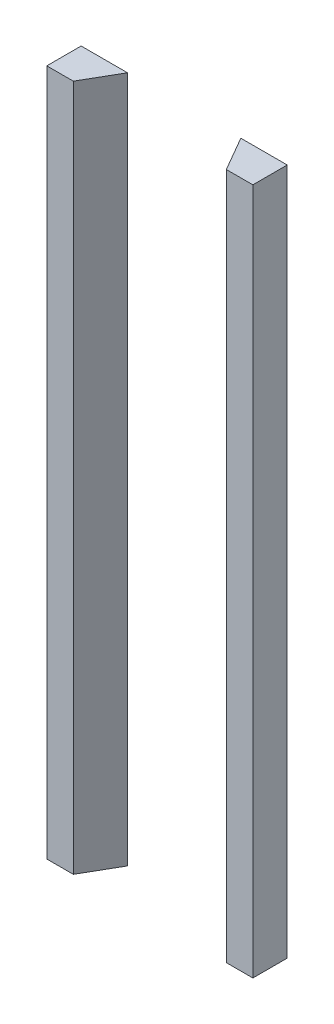
from build123d import *

# Parameters (mm, degrees)
SKETCH_1_W          = 60
SKETCH_1_H          = 10
EXTRUDE_1_DEPTH     = 200
CUT_EXTRUDE_1_REACH = 202


with BuildPart() as part:
    # 草图1 → 凸台-拉伸1 (new body)
    with BuildSketch(Plane(origin=(0, 0, 0), x_dir=(1, 0, 0), z_dir=(0, 1, 0))):
        Rectangle(SKETCH_1_W, SKETCH_1_H)
    extrude(amount=EXTRUDE_1_DEPTH)

    # 草图2 → 切除-拉伸1 (cut, up to next)
    with BuildSketch(Plane(origin=(0, 200, 0), x_dir=(1, 0, 0), z_dir=(0, 1, 0)), mode=Mode.PRIVATE) as cut_extrude_1_sk1:
        Polygon((-22.273502692, -5), (-16.5, 5), (16.5, 5), (22.273502692, -5), align=None)
    cut_extrude_1_tool1 = extrude(cut_extrude_1_sk1.sketch, amount=-CUT_EXTRUDE_1_REACH, mode=Mode.PRIVATE) & part.part
    add(cut_extrude_1_tool1.solids().sort_by_distance((0, 200, 0.248172))[0], mode=Mode.SUBTRACT)


solid = part.part
